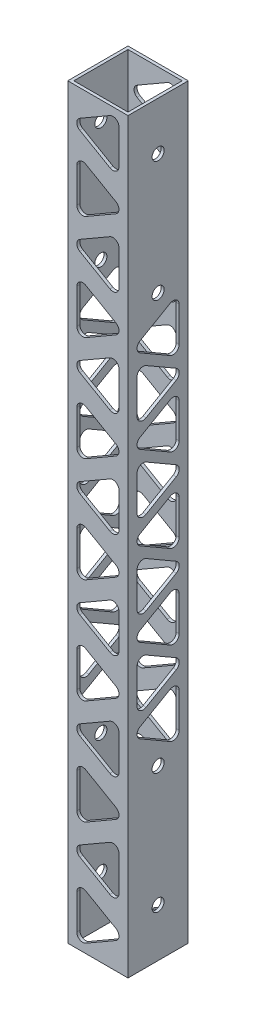
from build123d import *

# Parameters (mm, degrees)
SKETCH1_W           = 63.5
SKETCH1_H           = 63.5
SKETCH1_W_2         = 57.15
SKETCH1_H_2         = 57.15
BOSS_EXTRUDE1_DEPTH = 787.4
SKETCH2_R           = 6.35
CUT_EXTRUDE1_DEPTH  = 64.5
CUT_EXTRUDE2_DEPTH  = 71.12
CUT_EXTRUDE3_DEPTH  = 71.12


with BuildPart() as part:
    # Sketch1 → Boss-Extrude1 (new body)
    with BuildSketch(Plane(origin=(0, 0, 0), x_dir=(1, 0, 0), z_dir=(0, 1, 0))):
        Rectangle(SKETCH1_W, SKETCH1_H)
        Rectangle(SKETCH1_W_2, SKETCH1_H_2, mode=Mode.SUBTRACT)
    extrude(amount=BOSS_EXTRUDE1_DEPTH)

    # Sketch2 → Cut-Extrude1 (cut, through all)
    with BuildSketch(Plane.ZY.offset(31.75)):
        with Locations((0, 50.8)):
            Circle(SKETCH2_R)
        with Locations((0, 177.8)):
            Circle(SKETCH2_R)
        with Locations((0, 609.6)):
            Circle(SKETCH2_R)
        with Locations((0, 736.6)):
            Circle(SKETCH2_R)
    extrude(amount=-CUT_EXTRUDE1_DEPTH, mode=Mode.SUBTRACT)

    # Sketch3 → Cut-Extrude2 (cut)
    with BuildSketch(Plane(origin=(31.75, 0, 0), x_dir=(0, 0, -1), z_dir=(1, 0, 0))):
        with BuildLine():
            Line((-19.05, 212.005871047), (12.7, 193.675))
            ThreePointArc((12.7, 193.675), (19.05, 193.675), (22.225, 199.174261314))
            Line((22.225, 199.174261314), (22.225, 235.836003408))
            ThreePointArc((22.225, 235.836003408), (19.05, 241.335264722), (12.7, 241.335264722))
            Line((12.7, 241.335264722), (-19.05, 223.004393675))
            ThreePointArc((-19.05, 223.004393675), (-22.225, 217.505132361), (-19.05, 212.005871047))
        make_face()
        with BuildLine():
            Line((19.05, 266.998484187), (-12.7, 285.329355234))
            ThreePointArc((-12.7, 285.329355234), (-19.05, 285.329355234), (-22.225, 279.83009392))
            Line((-22.225, 279.83009392), (-22.225, 243.168351826))
            ThreePointArc((-22.225, 243.168351826), (-19.05, 237.669090512), (-12.7, 237.669090512))
            Line((-12.7, 237.669090512), (19.05, 255.999961559))
            ThreePointArc((19.05, 255.999961559), (22.225, 261.499222873), (19.05, 266.998484187))
        make_face()
        with BuildLine():
            Line((-19.05, 300.103304866), (12.7, 281.77243382))
            ThreePointArc((12.7, 281.77243382), (19.05, 281.77243382), (22.225, 287.271695134))
            Line((22.225, 287.271695134), (22.225, 323.933437227))
            ThreePointArc((22.225, 323.933437227), (19.05, 329.432698541), (12.7, 329.432698541))
            Line((12.7, 329.432698541), (-19.05, 311.101827494))
            ThreePointArc((-19.05, 311.101827494), (-22.225, 305.60256618), (-19.05, 300.103304866))
        make_face()
        with BuildLine():
            Line((19.05, 355.095918007), (-12.7, 373.426789053))
            ThreePointArc((-12.7, 373.426789053), (-19.05, 373.426789053), (-22.225, 367.927527739))
            Line((-22.225, 367.927527739), (-22.225, 331.265785646))
            ThreePointArc((-22.225, 331.265785646), (-19.05, 325.766524332), (-12.7, 325.766524332))
            Line((-12.7, 325.766524332), (19.05, 344.097395379))
            ThreePointArc((19.05, 344.097395379), (22.225, 349.596656693), (19.05, 355.095918007))
        make_face()
        with BuildLine():
            Line((-19.05, 388.200738686), (12.7, 369.869867639))
            ThreePointArc((12.7, 369.869867639), (19.05, 369.869867639), (22.225, 375.369128953))
            Line((22.225, 375.369128953), (22.225, 412.030871047))
            ThreePointArc((22.225, 412.030871047), (19.05, 417.530132361), (12.7, 417.530132361))
            Line((12.7, 417.530132361), (-19.05, 399.199261314))
            ThreePointArc((-19.05, 399.199261314), (-22.225, 393.7), (-19.05, 388.200738686))
        make_face()
        with BuildLine():
            Line((19.05, 443.193351826), (-12.7, 461.524222873))
            ThreePointArc((-12.7, 461.524222873), (-19.05, 461.524222873), (-22.225, 456.024961559))
            Line((-22.225, 456.024961559), (-22.225, 419.363219465))
            ThreePointArc((-22.225, 419.363219465), (-19.05, 413.863958151), (-12.7, 413.863958151))
            Line((-12.7, 413.863958151), (19.05, 432.194829198))
            ThreePointArc((19.05, 432.194829198), (22.225, 437.694090512), (19.05, 443.193351826))
        make_face()
        with BuildLine():
            Line((-19.05, 476.298172506), (12.7, 457.967301459))
            ThreePointArc((12.7, 457.967301459), (19.05, 457.967301459), (22.225, 463.466562773))
            Line((22.225, 463.466562773), (22.225, 500.128304866))
            ThreePointArc((22.225, 500.128304866), (19.05, 505.62756618), (12.7, 505.62756618))
            Line((12.7, 505.62756618), (-19.05, 487.296695134))
            ThreePointArc((-19.05, 487.296695134), (-22.225, 481.79743382), (-19.05, 476.298172506))
        make_face()
        with BuildLine():
            Line((19.05, 531.290785646), (-12.7, 549.621656693))
            ThreePointArc((-12.7, 549.621656693), (-19.05, 549.621656693), (-22.225, 544.122395379))
            Line((-22.225, 544.122395379), (-22.225, 507.460653285))
            ThreePointArc((-22.225, 507.460653285), (-19.05, 501.961391971), (-12.7, 501.961391971))
            Line((-12.7, 501.961391971), (19.05, 520.292263018))
            ThreePointArc((19.05, 520.292263018), (22.225, 525.791524332), (19.05, 531.290785646))
        make_face()
        with BuildLine():
            Line((-19.05, 564.395606325), (12.7, 546.064735278))
            ThreePointArc((12.7, 546.064735278), (19.05, 546.064735278), (22.225, 551.563996592))
            Line((22.225, 551.563996592), (22.225, 588.225738686))
            ThreePointArc((22.225, 588.225738686), (19.05, 593.725), (12.7, 593.725))
            Line((12.7, 593.725), (-19.05, 575.394128953))
            ThreePointArc((-19.05, 575.394128953), (-22.225, 569.894867639), (-19.05, 564.395606325))
        make_face()
    extrude(amount=-CUT_EXTRUDE2_DEPTH, mode=Mode.SUBTRACT)

    # Sketch5 → Cut-Extrude3 (cut)
    with BuildSketch(Plane(origin=(0, 0, -31.75), x_dir=(-1, 0, 0), z_dir=(0, 0, -1))):
        with BuildLine():
            Line((19.05, 759.544128953), (-12.7, 777.875))
            ThreePointArc((-12.7, 777.875), (-19.05, 777.875), (-22.225, 772.375738686))
            Line((-22.225, 772.375738686), (-22.225, 735.713996592))
            ThreePointArc((-22.225, 735.713996592), (-19.05, 730.214735278), (-12.7, 730.214735278))
            Line((-12.7, 730.214735278), (19.05, 748.545606325))
            ThreePointArc((19.05, 748.545606325), (22.225, 754.044867639), (19.05, 759.544128953))
        make_face()
        with BuildLine():
            Line((-19.05, 691.360341604), (12.7, 673.029470557))
            ThreePointArc((12.7, 673.029470557), (19.05, 673.029470557), (22.225, 678.528731871))
            Line((22.225, 678.528731871), (22.225, 715.190473964))
            ThreePointArc((22.225, 715.190473964), (19.05, 720.689735278), (12.7, 720.689735278))
            Line((12.7, 720.689735278), (-19.05, 702.358864232))
            ThreePointArc((-19.05, 702.358864232), (-22.225, 696.859602918), (-19.05, 691.360341604))
        make_face()
        with BuildLine():
            Line((19.05, 648.960050527), (-12.7, 667.290921574))
            ThreePointArc((-12.7, 667.290921574), (-19.05, 667.290921574), (-22.225, 661.79166026))
            Line((-22.225, 661.79166026), (-22.225, 625.129918166))
            ThreePointArc((-22.225, 625.129918166), (-19.05, 619.630656852), (-12.7, 619.630656852))
            Line((-12.7, 619.630656852), (19.05, 637.961527899))
            ThreePointArc((19.05, 637.961527899), (22.225, 643.460789213), (19.05, 648.960050527))
        make_face()
        with BuildLine():
            Line((-19.05, 580.776263177), (12.7, 562.445392131))
            ThreePointArc((12.7, 562.445392131), (19.05, 562.445392131), (22.225, 567.944653445))
            Line((22.225, 567.944653445), (22.225, 604.606395538))
            ThreePointArc((22.225, 604.606395538), (19.05, 610.105656852), (12.7, 610.105656852))
            Line((12.7, 610.105656852), (-19.05, 591.774785805))
            ThreePointArc((-19.05, 591.774785805), (-22.225, 586.275524491), (-19.05, 580.776263177))
        make_face()
        with BuildLine():
            Line((19.05, 538.375972101), (-12.7, 556.706843148))
            ThreePointArc((-12.7, 556.706843148), (-19.05, 556.706843148), (-22.225, 551.207581834))
            Line((-22.225, 551.207581834), (-22.225, 514.54583974))
            ThreePointArc((-22.225, 514.54583974), (-19.05, 509.046578426), (-12.7, 509.046578426))
            Line((-12.7, 509.046578426), (19.05, 527.377449473))
            ThreePointArc((19.05, 527.377449473), (22.225, 532.876710787), (19.05, 538.375972101))
        make_face()
        with BuildLine():
            Line((-19.05, 470.192184751), (12.7, 451.861313705))
            ThreePointArc((12.7, 451.861313705), (19.05, 451.861313705), (22.225, 457.360575019))
            Line((22.225, 457.360575019), (22.225, 494.022317112))
            ThreePointArc((22.225, 494.022317112), (19.05, 499.521578426), (12.7, 499.521578426))
            Line((12.7, 499.521578426), (-19.05, 481.190707379))
            ThreePointArc((-19.05, 481.190707379), (-22.225, 475.691446065), (-19.05, 470.192184751))
        make_face()
        with BuildLine():
            Line((19.05, 427.791893675), (-12.7, 446.122764722))
            ThreePointArc((-12.7, 446.122764722), (-19.05, 446.122764722), (-22.225, 440.623503408))
            Line((-22.225, 440.623503408), (-22.225, 403.961761314))
            ThreePointArc((-22.225, 403.961761314), (-19.05, 398.4625), (-12.7, 398.4625))
            Line((-12.7, 398.4625), (19.05, 416.793371047))
            ThreePointArc((19.05, 416.793371047), (22.225, 422.292632361), (19.05, 427.791893675))
        make_face()
        with BuildLine():
            Line((-19.05, 359.608106325), (12.7, 341.277235278))
            ThreePointArc((12.7, 341.277235278), (19.05, 341.277235278), (22.225, 346.776496592))
            Line((22.225, 346.776496592), (22.225, 383.438238686))
            ThreePointArc((22.225, 383.438238686), (19.05, 388.9375), (12.7, 388.9375))
            Line((12.7, 388.9375), (-19.05, 370.606628953))
            ThreePointArc((-19.05, 370.606628953), (-22.225, 365.107367639), (-19.05, 359.608106325))
        make_face()
        with BuildLine():
            Line((19.05, 317.207815249), (-12.7, 335.538686295))
            ThreePointArc((-12.7, 335.538686295), (-19.05, 335.538686295), (-22.225, 330.039424981))
            Line((-22.225, 330.039424981), (-22.225, 293.377682888))
            ThreePointArc((-22.225, 293.377682888), (-19.05, 287.878421574), (-12.7, 287.878421574))
            Line((-12.7, 287.878421574), (19.05, 306.209292621))
            ThreePointArc((19.05, 306.209292621), (22.225, 311.708553935), (19.05, 317.207815249))
        make_face()
        with BuildLine():
            Line((-19.05, 249.024027899), (12.7, 230.693156852))
            ThreePointArc((12.7, 230.693156852), (19.05, 230.693156852), (22.225, 236.192418166))
            Line((22.225, 236.192418166), (22.225, 272.85416026))
            ThreePointArc((22.225, 272.85416026), (19.05, 278.353421574), (12.7, 278.353421574))
            Line((12.7, 278.353421574), (-19.05, 260.022550527))
            ThreePointArc((-19.05, 260.022550527), (-22.225, 254.523289213), (-19.05, 249.024027899))
        make_face()
        with BuildLine():
            Line((19.05, 206.623736823), (-12.7, 224.954607869))
            ThreePointArc((-12.7, 224.954607869), (-19.05, 224.954607869), (-22.225, 219.455346555))
            Line((-22.225, 219.455346555), (-22.225, 182.793604462))
            ThreePointArc((-22.225, 182.793604462), (-19.05, 177.294343148), (-12.7, 177.294343148))
            Line((-12.7, 177.294343148), (19.05, 195.625214195))
            ThreePointArc((19.05, 195.625214195), (22.225, 201.124475509), (19.05, 206.623736823))
        make_face()
        with BuildLine():
            Line((-19.05, 138.439949473), (12.7, 120.109078426))
            ThreePointArc((12.7, 120.109078426), (19.05, 120.109078426), (22.225, 125.60833974))
            Line((22.225, 125.60833974), (22.225, 162.270081834))
            ThreePointArc((22.225, 162.270081834), (19.05, 167.769343148), (12.7, 167.769343148))
            Line((12.7, 167.769343148), (-19.05, 149.438472101))
            ThreePointArc((-19.05, 149.438472101), (-22.225, 143.939210787), (-19.05, 138.439949473))
        make_face()
        with BuildLine():
            Line((19.05, 96.039658396), (-12.7, 114.370529443))
            ThreePointArc((-12.7, 114.370529443), (-19.05, 114.370529443), (-22.225, 108.871268129))
            Line((-22.225, 108.871268129), (-22.225, 72.209526036))
            ThreePointArc((-22.225, 72.209526036), (-19.05, 66.710264722), (-12.7, 66.710264722))
            Line((-12.7, 66.710264722), (19.05, 85.041135768))
            ThreePointArc((19.05, 85.041135768), (22.225, 90.540397082), (19.05, 96.039658396))
        make_face()
        with BuildLine():
            Line((-19.05, 27.855871047), (12.7, 9.525))
            ThreePointArc((12.7, 9.525), (19.05, 9.525), (22.225, 15.024261314))
            Line((22.225, 15.024261314), (22.225, 51.686003408))
            ThreePointArc((22.225, 51.686003408), (19.05, 57.185264722), (12.7, 57.185264722))
            Line((12.7, 57.185264722), (-19.05, 38.854393675))
            ThreePointArc((-19.05, 38.854393675), (-22.225, 33.355132361), (-19.05, 27.855871047))
        make_face()
    extrude(amount=-CUT_EXTRUDE3_DEPTH, mode=Mode.SUBTRACT)


solid = part.part
